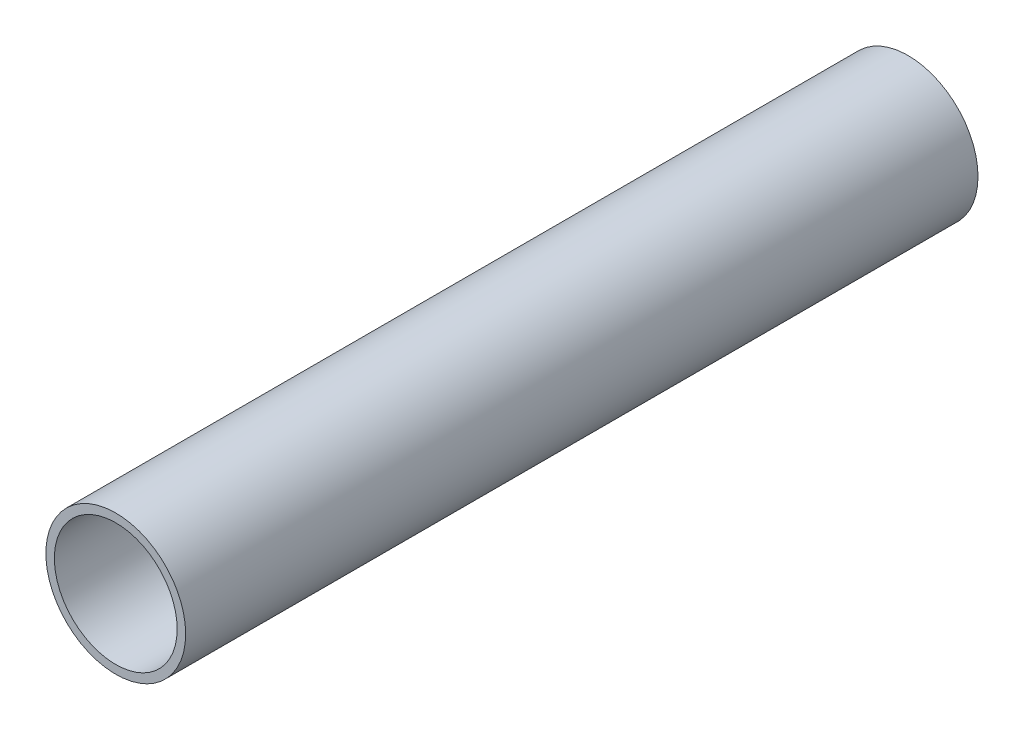
from build123d import *

# Parameters (mm, degrees)
SKETCH1_R           = 12.35
SKETCH1_R_2         = 10.85
BOSS_EXTRUDE1_DEPTH = 140


with BuildPart() as part:
    # Sketch1 → Boss-Extrude1 (new body)
    with BuildSketch(Plane.XY):
        Circle(SKETCH1_R)
        Circle(SKETCH1_R_2, mode=Mode.SUBTRACT)
    extrude(amount=BOSS_EXTRUDE1_DEPTH)


solid = part.part
